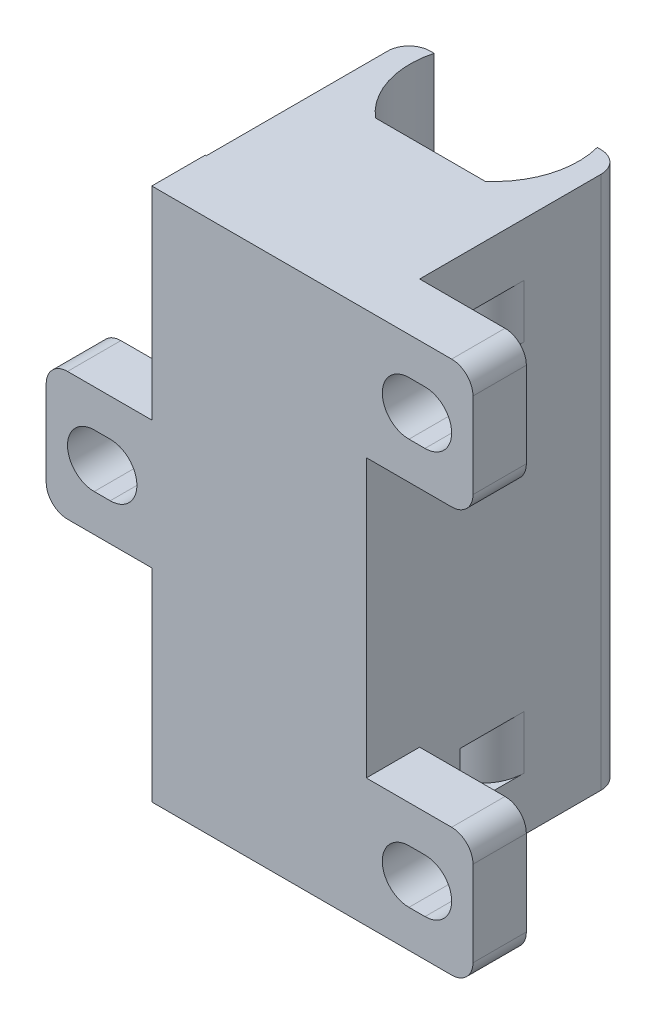
from build123d import *

# Parameters (mm, degrees)
BOSS_EXTRUDE1_DEPTH = 50
SKETCH2_W           = 15.285287044
SKETCH2_H           = 2
BOSS_EXTRUDE2_DEPTH = 10
FILLET1_R           = 2
SKETCH3_W           = 10
SKETCH3_H           = 26
SKETCH3_W_2         = 9.897545425
SKETCH3_H_2         = 19
CUT_EXTRUDE1_DEPTH  = 6
SKETCH4_W           = 2
SKETCH4_H           = 5
CUT_EXTRUDE2_DEPTH  = 31
FILLET2_R           = 4
FILLET3_R           = 2


with BuildPart() as part:
    # Sketch1 → Boss-Extrude1 (new body)
    with BuildSketch(Plane(origin=(0, 0, 0), x_dir=(1, 0, 0), z_dir=(0, 1, 0))):
        with BuildLine():
            Line((-5.276963181, 0), (34.723036819, 0))
            Line((34.723036819, 0), (34.723036819, 5))
            Line((34.723036819, 5), (24.723036819, 5))
            Line((24.723036819, 5), (24.723036819, 24))
            Line((24.723036819, 24), (22.365680341, 24))
            ThreePointArc((22.365680341, 24), (14.723036819, 14.1), (7.080393297, 24))
            Line((7.080393297, 24), (4.723036819, 24))
            Line((4.723036819, 24), (4.723036819, 5))
            Line((4.723036819, 5), (-5.276963181, 5))
            Line((-5.276963181, 5), (-5.276963181, 0))
        make_face()
    extrude(amount=BOSS_EXTRUDE1_DEPTH)

    # Sketch2 → Boss-Extrude2 (add)
    with BuildSketch(Plane(origin=(0, 0, -16), x_dir=(-1, 0, 0), z_dir=(0, 0, -1))):
        with Locations((-14.723036819, 49)):
            Rectangle(SKETCH2_W, SKETCH2_H)
        with Locations((-14.723036819, 1)):
            Rectangle(SKETCH2_W, SKETCH2_H)
    extrude(amount=-BOSS_EXTRUDE2_DEPTH)

    # Fillet1
    fillet1_edges = [part.edges().sort_by_distance(p)[0] for p in [
        (34.723036819, 50, -2.5),
        (34.723036819, 0, -2.5),
        (-5.276963181, 0, -2.5),
        (4.723036819, 25, -24),
        (24.723036819, 25, -24),
        (-5.276963181, 50, -2.5),
    ]]
    fillet(fillet1_edges, radius=FILLET1_R)

    # Sketch3 → Cut-Extrude1 (cut, through all)
    with BuildSketch(Plane(origin=(0, 0, -5), x_dir=(-1, 0, 0), z_dir=(0, 0, -1))):
        with BuildLine():
            Line((-0.723036819, 27.5), (0.776963181, 27.5))
            ThreePointArc((0.776963181, 27.5), (3.276963181, 25), (0.776963181, 22.5))
            Line((0.776963181, 22.5), (-0.723036819, 22.5))
            ThreePointArc((-0.723036819, 22.5), (-3.223036819, 25), (-0.723036819, 27.5))
        make_face()
        with BuildLine():
            Line((-30.223036819, 46.5), (-28.723036819, 46.5))
            ThreePointArc((-28.723036819, 46.5), (-26.223036819, 44), (-28.723036819, 41.5))
            Line((-28.723036819, 41.5), (-30.223036819, 41.5))
            ThreePointArc((-30.223036819, 41.5), (-32.723036819, 44), (-30.223036819, 46.5))
        make_face()
        with Locations((-29.723036819, 25)):
            Rectangle(SKETCH3_W, SKETCH3_H)
        with BuildLine():
            Line((-30.223036819, 8.5), (-28.723036819, 8.5))
            ThreePointArc((-28.723036819, 8.5), (-26.223036819, 6), (-28.723036819, 3.5))
            Line((-28.723036819, 3.5), (-30.223036819, 3.5))
            ThreePointArc((-30.223036819, 3.5), (-32.723036819, 6), (-30.223036819, 8.5))
        make_face()
        with Locations((0.328190468, 40.5)):
            Rectangle(SKETCH3_W_2, SKETCH3_H_2)
        with Locations((0.328190468, 9.5)):
            Rectangle(SKETCH3_W_2, SKETCH3_H_2)
    extrude(amount=-CUT_EXTRUDE1_DEPTH, mode=Mode.SUBTRACT)

    # Sketch4 → Cut-Extrude2 (cut, through all)
    with BuildSketch(Plane.ZY.offset(-4.723036819)):
        with Locations((-9.802694021, 42.5)):
            Rectangle(SKETCH4_W, SKETCH4_H)
        with Locations((-9.802694021, 7.5)):
            Rectangle(SKETCH4_W, SKETCH4_H)
    extrude(amount=-CUT_EXTRUDE2_DEPTH, mode=Mode.SUBTRACT)

    # Fillet2
    fillet2_edges = [part.edges().sort_by_distance(p)[0] for p in [
        (24.723036819, 42.5, -10.802694021),
        (4.723036819, 42.5, -10.802694021),
        (24.723036819, 7.5, -10.802694021),
        (4.723036819, 7.5, -10.802694021),
    ]]
    fillet(fillet2_edges, radius=FILLET2_R)

    # Fillet3
    fillet3_edges = [part.edges().sort_by_distance(p)[0] for p in [
        (34.723036819, 12, -2.5),
        (34.723036819, 38, -2.5),
        (-5.276963181, 31, -2.5),
        (-5.276963181, 19, -2.5),
    ]]
    fillet(fillet3_edges, radius=FILLET3_R)


solid = part.part
